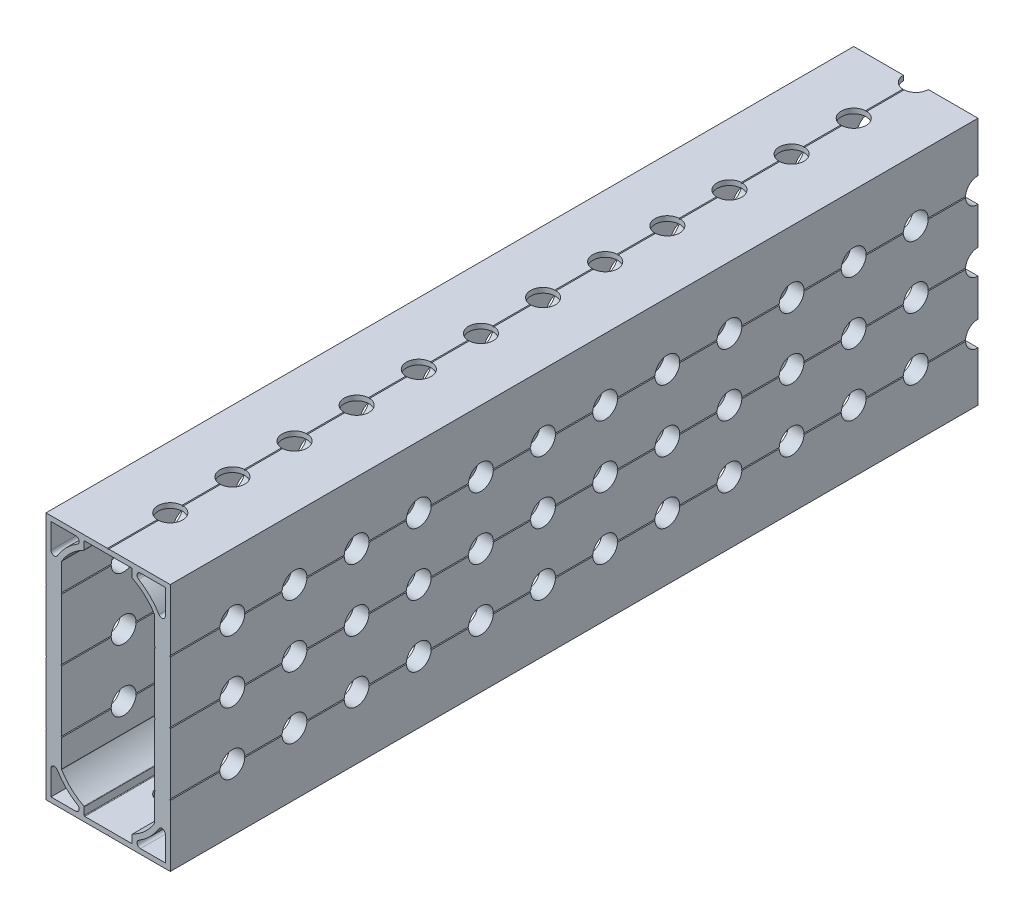
from build123d import *

# Parameters (mm, degrees)
SKETCH1_W                                = 50.8
SKETCH1_H                                = 165.1
BOSS_EXTRUDE1_DEPTH                      = 25.4
CUT_EXTRUDE1_DEPTH                       = 166.1
CUT_EXTRUDE9_DEPTH                       = 166.1
MIRROR1_AT_THE_SECOND_PLANE_COPY_1_DEPTH = 166.1
CUT_EXTRUDE11_START                      = -26.4
SKETCH17_R                               = 2.54
CUT_EXTRUDE11_DEPTH                      = 27.4
SKETCH18_R                               = 2.54
CUT_EXTRUDE12_DEPTH                      = 51.8
LPATTERN1_COUNT                          = 14
LPATTERN1_PITCH                          = 12.7
LPATTERN2_COUNT                          = 14
LPATTERN2_PITCH                          = 12.7
LPATTERN2_COUNT_DIR2                     = 3
LPATTERN2_PITCH_DIR2                     = 12.7
FILLET1_R                                = 0.127


with BuildPart() as part:
    # Sketch1 → Boss-Extrude1 (new body)
    with BuildSketch(Plane(origin=(-12.7, 0, 0), x_dir=(0, -1, 0), z_dir=(-1, 0, 0))):
        Rectangle(SKETCH1_W, SKETCH1_H)
    extrude(amount=-BOSS_EXTRUDE1_DEPTH)

    # Sketch2 → Cut-Extrude1 (cut, through all)
    with BuildSketch(Plane(origin=(0, 0, -82.55), x_dir=(-1, 0, 0), z_dir=(0, 0, -1))):
        Polygon((-12.7, -12.573), (-12.7, -12.827), (-12.573, -12.7), align=None)
        Polygon((-0.127, 0), (0.127, 0), (0, 0.127), align=None)
        Polygon((12.7, -12.827), (12.7, -12.573), (12.573, -12.7), align=None)
        Polygon((-12.7, 0.127), (-12.7, -0.127), (-12.573, 0), align=None)
        Polygon((-12.7, 12.827), (-12.7, 12.573), (-12.573, 12.7), align=None)
        Polygon((12.7, -0.127), (12.7, 0.127), (12.573, 0), align=None)
        Polygon((12.7, 12.573), (12.7, 12.827), (12.573, 12.7), align=None)
        Polygon((-0.127, 25.4), (0.127, 25.4), (0, 25.273), align=None)
    extrude(amount=-CUT_EXTRUDE1_DEPTH, mode=Mode.SUBTRACT)

    # Sketch10 → Cut-Extrude9 (cut, through all)
    with BuildSketch(Plane.XY.offset(82.55)):
        with BuildLine():
            Line((-11.684, 24.384), (-11.684, 19.297089026))
            ThreePointArc((-11.684, 19.297089026), (-11.177055919, 18.630604499), (-10.39941737, 18.941204261))
            ThreePointArc((-10.39941737, 18.941204261), (-8.576144596, 21.276144596), (-6.241204261, 23.09941737))
            ThreePointArc((-6.241204261, 23.09941737), (-5.930604499, 23.877055919), (-6.597089026, 24.384))
            Line((-6.597089026, 24.384), (-11.684, 24.384))
        make_face()
        Polygon((-12.7, 0.127), (-12.7, 0), (-12.573, 0), align=None)
        Polygon((-12.7, 12.827), (-12.573, 12.7), (-12.7, 12.573), align=None)
        Polygon((0.127, 25.4), (0, 25.273), (-0.127, 25.4), align=None)
        with BuildLine():
            Line((0, 24.384), (-4.8895, 24.384))
            Line((-4.8895, 24.384), (-4.8895, 22.679000251))
            ThreePointArc((-4.8895, 22.679000251), (-7.514726072, 20.886363558), (-9.525, 18.42381265))
            Line((-9.525, 18.42381265), (-9.525, 12.827))
            Line((-9.525, 12.827), (-9.652, 12.7))
            Line((-9.652, 12.7), (-9.525, 12.573))
            Line((-9.525, 12.573), (-9.525, 0.127))
            Line((-9.525, 0.127), (-9.652, 0))
            Line((-9.652, 0), (0, 0))
            Line((0, 0), (0, 24.384))
        make_face()
    cut_extrude9 = extrude(amount=-CUT_EXTRUDE9_DEPTH, mode=Mode.SUBTRACT)

    # Mirror1: Cut-Extrude9 across plane
    add(cut_extrude9.mirror(Plane.ZX), mode=Mode.SUBTRACT)

    # Mirror1 at the second plane: Cut-Extrude9 across plane
    add(cut_extrude9.mirror(Plane(origin=(0, 0, 0), x_dir=(0, 0, 1), z_dir=(1, 0, 0))), mode=Mode.SUBTRACT)

    # Mirror1 at the second plane copy 1 sketc → Mirror1 at the second plane copy 1 (cut, through all)
    with BuildSketch(Plane(origin=(0, 0, 82.55), x_dir=(-1, 0, 0), z_dir=(0, 0, 1))):
        with BuildLine():
            Line((-11.684, 24.384), (-11.684, 19.297089026))
            ThreePointArc((-11.684, 19.297089026), (-11.177055919, 18.630604499), (-10.39941737, 18.941204261))
            ThreePointArc((-10.39941737, 18.941204261), (-8.576144596, 21.276144596), (-6.241204261, 23.09941737))
            ThreePointArc((-6.241204261, 23.09941737), (-5.930604499, 23.877055919), (-6.597089026, 24.384))
            Line((-6.597089026, 24.384), (-11.684, 24.384))
        make_face()
        Polygon((-12.7, 0.127), (-12.7, 0), (-12.573, 0), align=None)
        Polygon((-12.7, 12.827), (-12.573, 12.7), (-12.7, 12.573), align=None)
        Polygon((0.127, 25.4), (0, 25.273), (-0.127, 25.4), align=None)
        with BuildLine():
            Line((0, 24.384), (-4.8895, 24.384))
            Line((-4.8895, 24.384), (-4.8895, 22.679000251))
            ThreePointArc((-4.8895, 22.679000251), (-7.514726072, 20.886363558), (-9.525, 18.42381265))
            Line((-9.525, 18.42381265), (-9.525, 12.827))
            Line((-9.525, 12.827), (-9.652, 12.7))
            Line((-9.652, 12.7), (-9.525, 12.573))
            Line((-9.525, 12.573), (-9.525, 0.127))
            Line((-9.525, 0.127), (-9.652, 0))
            Line((-9.652, 0), (0, 0))
            Line((0, 0), (0, 24.384))
        make_face()
    extrude(amount=-MIRROR1_AT_THE_SECOND_PLANE_COPY_1_DEPTH, mode=Mode.SUBTRACT)

    # Sketch17 → Cut-Extrude11 (cut)
    with BuildSketch(Plane(origin=(12.7, 0, 0), x_dir=(0, 0, -1), z_dir=(1, 0, 0)).offset(CUT_EXTRUDE11_START)):
        with Locations((-69.85, 12.7)):
            Circle(SKETCH17_R)
    cut_extrude11 = extrude(amount=CUT_EXTRUDE11_DEPTH, mode=Mode.SUBTRACT)

    # Sketch18 → Cut-Extrude12 (cut, through all)
    with BuildSketch(Plane(origin=(0, 25.4, 0), x_dir=(1, 0, 0), z_dir=(0, 1, 0))):
        with Locations((0, -69.85)):
            Circle(SKETCH18_R)
    cut_extrude12 = extrude(amount=-CUT_EXTRUDE12_DEPTH, mode=Mode.SUBTRACT)

    # LPattern1: Cut-Extrude12 ×14
    with Locations(*[(0, 0, -i * LPATTERN1_PITCH) for i in range(1, LPATTERN1_COUNT)]):
        add(cut_extrude12, mode=Mode.SUBTRACT)

    # LPattern2: Cut-Extrude11 14 × 3
    with Locations(*[(0, -j * LPATTERN2_PITCH_DIR2, -i * LPATTERN2_PITCH) for i in range(LPATTERN2_COUNT) for j in range(LPATTERN2_COUNT_DIR2) if (i, j) != (0, 0)]):
        add(cut_extrude11, mode=Mode.SUBTRACT)

    # Fillet1
    fillet1_edges = [part.edges().sort_by_distance(p)[0] for p in [
        (-4.8895, 22.679000251, 0),
        (-4.8895, 24.384, 0),
        (-9.525, 18.42381265, 0),
        (4.8895, 24.384, 0),
        (4.8895, 22.679000251, 0),
        (9.525, 18.42381265, 0),
        (-4.8895, -24.384, 0),
        (-4.8895, -22.679000251, 0),
        (-9.525, -18.42381265, 0),
        (4.8895, -22.679000251, 0),
        (4.8895, -24.384, 0),
        (9.525, -18.42381265, 0),
    ]]
    fillet(fillet1_edges, radius=FILLET1_R)


solid = part.part
